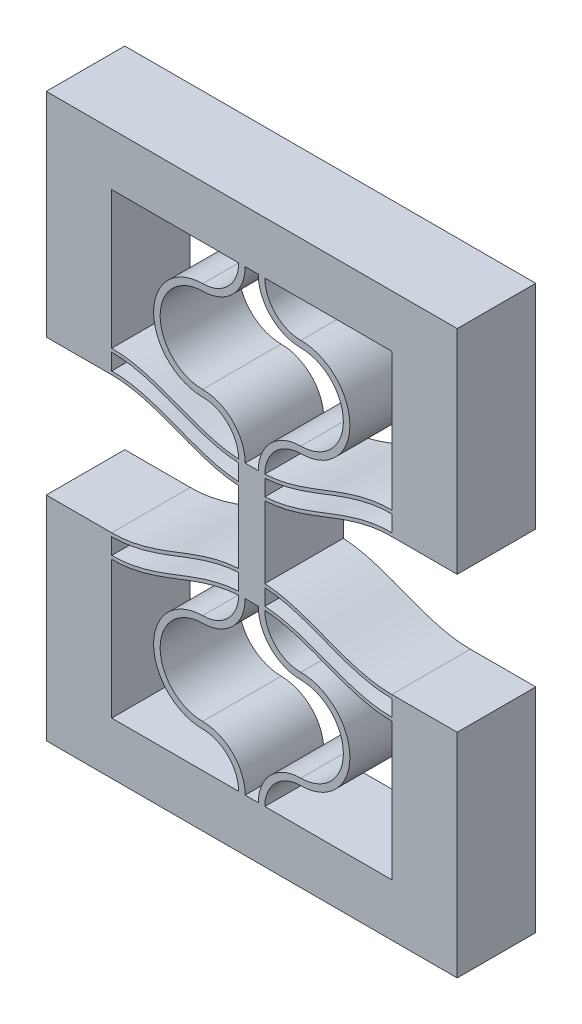
from build123d import *

# Parameters (mm, degrees)
BOSS_EXTRUDE1_DEPTH = 6
SKETCH4_W           = 1.000079602
SKETCH4_H           = 6
BOSS_EXTRUDE2_DEPTH = 1.5
SKETCH7_W           = 6
SKETCH7_H           = 4
SKETCH7_H_2         = 8.970409071
BOSS_EXTRUDE3_DEPTH = 0.5


with BuildPart() as part:
    # Sketch1 → Boss-Extrude1 (new body)
    with BuildSketch(Plane.XY):
        with BuildLine():
            add(Edge.make_bspline(
                [(10.700039975, 14.745204536), (10.770772559, 14.741026808), (11.036928883, 14.722362813), (11.497122592, 14.671037325), (12.289279781, 14.528352814), (13.186428125, 14.281886639), (13.972953946, 14.012479628), (14.659814487, 13.755888369), (15.208666695, 13.545451258), (15.665563716, 13.368818224), (16.123450769, 13.194753096), (16.65208653, 13.002369042), (17.160327646, 12.828079612), (17.673887847, 12.669729106), (18.193716878, 12.533320658), (18.599888692, 12.444944264), (18.888931626, 12.391496574), (19.130919694, 12.353423685), (19.325052629, 12.327000657), (19.519580514, 12.304753805), (19.715757224, 12.286804034), (19.909026191, 12.273251391), (20.101721437, 12.264172749), (20.275673832, 12.260758352), (20.359000366, 12.259999604), (20.4, 12.259999604)],
                knots=[0.519813033, 0.519813033, 0.519813033, 0.519813033, 0.519813033, 0.531036625, 0.562073255, 0.593109869, 0.647173692, 0.678210339, 0.693728663, 0.709246987, 0.740283631, 0.755801952, 0.771320274, 0.79835218, 0.825384086, 0.84090241, 0.856420734, 0.86417989, 0.871939045, 0.8796982, 0.887457356, 0.89521651, 0.902975665, 0.910734819, 0.918493974, 0.918493974, 0.918493974, 0.918493974, 0.918493974], degree=4))
            Line((10.700039975, 14.745204536), (10.700039975, 15.985204536))
            Line((10.700039975, 15.985204536), (9.699960373, 15.985204536))
            Line((9.699960373, 15.985204536), (9.699960373, 14.745204536))
            add(Edge.make_bspline(
                [(0, 12.259999604), (0.040999634, 12.259999604), (0.124259479, 12.260758348), (0.355363371, 12.265310827), (0.583318983, 12.278545215), (0.832717182, 12.299192103), (1.123166493, 12.332562429), (1.414830156, 12.374284724), (1.752116289, 12.434526897), (2.206359313, 12.533321163), (2.726048123, 12.669728195), (3.239713703, 12.828081076), (3.7478924, 13.002367086), (4.184493287, 13.161250769), (4.551277809, 13.299188315), (4.917195343, 13.439475144), (5.282809261, 13.580521779), (5.740185056, 13.755889696), (6.427046416, 14.012478612), (7.213571652, 14.281887279), (8.110720324, 14.528352483), (8.902877469, 14.671037458), (9.363071278, 14.722362846), (9.629227699, 14.741026811), (9.699960373, 14.745204536)],
                knots=[0.081506026, 0.081506026, 0.081506026, 0.081506026, 0.081506026, 0.089265181, 0.097024335, 0.112542644, 0.1203018, 0.128060955, 0.143579266, 0.15909759, 0.174615914, 0.20164782, 0.228679726, 0.244198048, 0.259716369, 0.275234691, 0.290753013, 0.306271337, 0.321789661, 0.352826308, 0.406890131, 0.437926745, 0.468963375, 0.480186981, 0.480186981, 0.480186981, 0.480186981, 0.480186981], degree=4))
            Line((0, 12.259999604), (-5.000000005, 12.259999604))
            Line((-5.000000005, 12.259999604), (-5.000000005, -4))
            Line((-5.000000005, -4), (25.400000005, -4))
            Line((25.400000005, -4), (25.400000005, 12.259999604))
            Line((25.400000005, 12.259999604), (20.4, 12.259999604))
        make_face()
        with BuildLine():
            Line((9.699960373, 14.485204536), (9.699960373, 13.245204536))
            add(Edge.make_bspline(
                [(0, 10.759999604), (0.040999634, 10.759999604), (0.124259479, 10.760758348), (0.355363371, 10.765310827), (0.583318983, 10.778545215), (0.832717182, 10.799192103), (1.123166493, 10.832562429), (1.414830156, 10.874284724), (1.752116289, 10.934526897), (2.206359313, 11.033321163), (2.726048123, 11.169728195), (3.239713703, 11.328081076), (3.7478924, 11.502367086), (4.184493287, 11.661250769), (4.551277809, 11.799188315), (4.917195343, 11.939475144), (5.282809261, 12.080521779), (5.740185056, 12.255889696), (6.427046416, 12.512478612), (7.213571652, 12.781887279), (8.110720324, 13.028352483), (8.902877469, 13.171037458), (9.363071278, 13.222362846), (9.629227699, 13.241026811), (9.699960373, 13.245204536)],
                knots=[0.081506026, 0.081506026, 0.081506026, 0.081506026, 0.081506026, 0.089265181, 0.097024335, 0.112542644, 0.1203018, 0.128060955, 0.143579266, 0.15909759, 0.174615914, 0.20164782, 0.228679726, 0.244198048, 0.259716369, 0.275234691, 0.290753013, 0.306271337, 0.321789661, 0.352826308, 0.406890131, 0.437926745, 0.468963375, 0.480186981, 0.480186981, 0.480186981, 0.480186981, 0.480186981], degree=4))
            Line((0, 10.759999604), (0, 11.999999604))
            add(Edge.make_bspline(
                [(0, 11.999999604), (0.040999634, 11.999999604), (0.124259479, 12.000758348), (0.355363371, 12.005310827), (0.583318983, 12.018545215), (0.832717182, 12.039192103), (1.123166493, 12.072562429), (1.414830156, 12.114284724), (1.752116289, 12.174526897), (2.206359313, 12.273321163), (2.726048123, 12.409728195), (3.239713703, 12.568081076), (3.7478924, 12.742367086), (4.184493287, 12.901250769), (4.551277809, 13.039188315), (4.917195343, 13.179475144), (5.282809261, 13.320521779), (5.740185056, 13.495889696), (6.427046416, 13.752478612), (7.213571652, 14.021887279), (8.110720324, 14.268352483), (8.902877469, 14.411037458), (9.363071278, 14.462362846), (9.629227699, 14.481026811), (9.699960373, 14.485204536)],
                knots=[0.081506026, 0.081506026, 0.081506026, 0.081506026, 0.081506026, 0.089265181, 0.097024335, 0.112542644, 0.1203018, 0.128060955, 0.143579266, 0.15909759, 0.174615914, 0.20164782, 0.228679726, 0.244198048, 0.259716369, 0.275234691, 0.290753013, 0.306271337, 0.321789661, 0.352826308, 0.406890131, 0.437926745, 0.468963375, 0.480186981, 0.480186981, 0.480186981, 0.480186981, 0.480186981], degree=4))
        make_face(mode=Mode.SUBTRACT)
        with BuildLine():
            Line((10.700039975, 13.245204536), (10.700039975, 14.485204536))
            add(Edge.make_bspline(
                [(10.700039975, 14.485204536), (10.770772559, 14.481026808), (11.036928883, 14.462362813), (11.497122592, 14.411037325), (12.289279781, 14.268352814), (13.186428125, 14.021886639), (13.972953947, 13.752479628), (14.659814487, 13.495888369), (15.208666695, 13.285451258), (15.665563716, 13.108818224), (16.123450769, 12.934753096), (16.65208653, 12.742369042), (17.160327646, 12.568079612), (17.673887847, 12.409729106), (18.193716878, 12.273320658), (18.599888692, 12.184944264), (18.888931626, 12.131496574), (19.130919694, 12.093423685), (19.325052629, 12.067000657), (19.519580514, 12.044753805), (19.715757224, 12.026804034), (19.909026191, 12.013251391), (20.101721437, 12.004172749), (20.275673832, 12.000758352), (20.359000366, 11.999999604), (20.4, 11.999999604)],
                knots=[0.519813033, 0.519813033, 0.519813033, 0.519813033, 0.519813033, 0.531036625, 0.562073255, 0.593109869, 0.647173692, 0.678210339, 0.693728663, 0.709246987, 0.740283631, 0.755801952, 0.771320274, 0.79835218, 0.825384086, 0.84090241, 0.856420734, 0.86417989, 0.871939045, 0.8796982, 0.887457356, 0.89521651, 0.902975665, 0.910734819, 0.918493974, 0.918493974, 0.918493974, 0.918493974, 0.918493974], degree=4))
            Line((20.4, 11.999999604), (20.4, 10.759999604))
            add(Edge.make_bspline(
                [(10.700039975, 13.245204536), (10.770772559, 13.241026808), (11.036928883, 13.222362813), (11.497122592, 13.171037325), (12.289279781, 13.028352814), (13.186428125, 12.781886639), (13.972953947, 12.512479628), (14.659814487, 12.255888369), (15.208666695, 12.045451258), (15.665563716, 11.868818224), (16.123450769, 11.694753096), (16.65208653, 11.502369042), (17.160327646, 11.328079612), (17.673887847, 11.169729106), (18.193716878, 11.033320658), (18.599888692, 10.944944264), (18.888931626, 10.891496574), (19.130919694, 10.853423685), (19.325052629, 10.827000657), (19.519580514, 10.804753805), (19.715757224, 10.786804034), (19.909026191, 10.773251391), (20.101721437, 10.764172749), (20.275673832, 10.760758352), (20.359000366, 10.759999604), (20.4, 10.759999604)],
                knots=[0.519813033, 0.519813033, 0.519813033, 0.519813033, 0.519813033, 0.531036625, 0.562073255, 0.593109869, 0.647173692, 0.678210339, 0.693728663, 0.709246987, 0.740283631, 0.755801952, 0.771320274, 0.79835218, 0.825384086, 0.84090241, 0.856420734, 0.86417989, 0.871939045, 0.8796982, 0.887457356, 0.89521651, 0.902975665, 0.910734819, 0.918493974, 0.918493974, 0.918493974, 0.918493974, 0.918493974], degree=4))
        make_face(mode=Mode.SUBTRACT)
        with BuildLine():
            Line((0, 0), (0, 10.499999604))
            add(Edge.make_bspline(
                [(0, 10.499999604), (0.040999634, 10.499999604), (0.124259479, 10.500758348), (0.355363371, 10.505310827), (0.583318983, 10.518545215), (0.832717182, 10.539192103), (1.123166493, 10.572562429), (1.414830156, 10.614284724), (1.752116289, 10.674526897), (2.206359313, 10.773321163), (2.726048123, 10.909728195), (3.239713703, 11.068081076), (3.7478924, 11.242367086), (4.184493287, 11.401250769), (4.551277809, 11.539188315), (4.917195343, 11.679475144), (5.282809261, 11.820521779), (5.740185056, 11.995889696), (6.427046416, 12.252478612), (7.213571652, 12.521887279), (8.110720324, 12.768352483), (8.902877469, 12.911037458), (9.363071278, 12.962362846), (9.629227699, 12.981026811), (9.699960373, 12.985204536)],
                knots=[0.081506026, 0.081506026, 0.081506026, 0.081506026, 0.081506026, 0.089265181, 0.097024335, 0.112542644, 0.1203018, 0.128060955, 0.143579266, 0.15909759, 0.174615914, 0.20164782, 0.228679726, 0.244198048, 0.259716369, 0.275234691, 0.290753013, 0.306271337, 0.321789661, 0.352826308, 0.406890131, 0.437926745, 0.468963375, 0.480186981, 0.480186981, 0.480186981, 0.480186981, 0.480186981], degree=4))
            ThreePointArc((9.699960373, 12.985204536), (8.889305781, 11.050232382), (6.950000174, 10.25))
            ThreePointArc((6.950000174, 10.25), (3.200000174, 6.5), (6.950000174, 2.75))
            ThreePointArc((6.950000174, 2.75), (8.894543822, 1.944543648), (9.700000174, 0))
            Line((9.700000174, 0), (0, 0))
        make_face(mode=Mode.SUBTRACT)
        with BuildLine():
            ThreePointArc((6.950000174, 9.75), (9.248097213, 10.701902961), (10.200000174, 13))
            ThreePointArc((10.200000174, 13), (11.151903135, 10.701902961), (13.450000174, 9.75))
            ThreePointArc((13.450000174, 9.75), (16.700000174, 6.5), (13.450000174, 3.25))
            ThreePointArc((13.450000174, 3.25), (11.151903135, 2.298097039), (10.200000174, 0))
            ThreePointArc((10.200000174, 0), (9.248097213, 2.298097039), (6.950000174, 3.25))
            ThreePointArc((6.950000174, 3.25), (3.700000174, 6.5), (6.950000174, 9.75))
        make_face(mode=Mode.SUBTRACT)
        with BuildLine():
            ThreePointArc((13.450000174, 10.25), (11.510694567, 11.050232382), (10.700039975, 12.985204536))
            add(Edge.make_bspline(
                [(10.700039975, 12.985204536), (10.770772559, 12.981026808), (11.036928883, 12.962362813), (11.497122592, 12.911037325), (12.289279781, 12.768352814), (13.186428125, 12.521886639), (13.972953947, 12.252479628), (14.659814487, 11.995888369), (15.208666695, 11.785451258), (15.665563716, 11.608818224), (16.123450769, 11.434753096), (16.65208653, 11.242369042), (17.160327646, 11.068079612), (17.673887847, 10.909729106), (18.193716878, 10.773320658), (18.599888692, 10.684944264), (18.888931626, 10.631496574), (19.130919694, 10.593423685), (19.325052629, 10.567000657), (19.519580514, 10.544753805), (19.715757224, 10.526804034), (19.909026191, 10.513251391), (20.101721437, 10.504172749), (20.275673832, 10.500758352), (20.359000366, 10.499999604), (20.4, 10.499999604)],
                knots=[0.519813033, 0.519813033, 0.519813033, 0.519813033, 0.519813033, 0.531036625, 0.562073255, 0.593109869, 0.647173692, 0.678210339, 0.693728663, 0.709246987, 0.740283631, 0.755801952, 0.771320274, 0.79835218, 0.825384086, 0.84090241, 0.856420734, 0.86417989, 0.871939045, 0.8796982, 0.887457356, 0.89521651, 0.902975665, 0.910734819, 0.918493974, 0.918493974, 0.918493974, 0.918493974, 0.918493974], degree=4))
            Line((20.4, 10.499999604), (20.4, 0))
            Line((20.4, 0), (10.700000174, 0))
            ThreePointArc((10.700000174, 0), (11.505456526, 1.944543648), (13.450000174, 2.75))
            ThreePointArc((13.450000174, 2.75), (17.200000174, 6.5), (13.450000174, 10.25))
        make_face(mode=Mode.SUBTRACT)
    extrude(amount=BOSS_EXTRUDE1_DEPTH)

    # Sketch4 → Boss-Extrude2 (add)
    with BuildSketch(Plane(origin=(0, 15.985204536, 0), x_dir=(1, 0, 0), z_dir=(0, 1, 0))):
        with Locations((10.200000174, -3)):
            Rectangle(SKETCH4_W, SKETCH4_H)
    extrude(amount=BOSS_EXTRUDE2_DEPTH)

    # Mirror3: part across plane


with BuildPart() as part_1:
    add(part.part)
    add(part.part.mirror(Plane.ZX.offset(17.485204536)))

    # Split2
    split(bisect_by=Plane(origin=(10.200000174, 0, 0), x_dir=(0, -1, 0), z_dir=(-1, 0, 0)), keep=Keep.BOTTOM)

    # Sketch7 → Boss-Extrude3 (add)
    with BuildSketch(Plane.ZY.offset(-10.200000174)):
        with Locations((3, 36.970409071)):
            Rectangle(SKETCH7_W, SKETCH7_H)
        with Locations((3, 17.485204536)):
            Rectangle(SKETCH7_W, SKETCH7_H_2)
        with Locations((3, -2)):
            Rectangle(SKETCH7_W, SKETCH7_H)
    extrude(amount=BOSS_EXTRUDE3_DEPTH)

    # Mirror2: part across plane


with BuildPart() as part_2:
    add(part_1.part)
    add(part_1.part.mirror(Plane.ZY.offset(-9.700000174)))


solid = part_2.part
